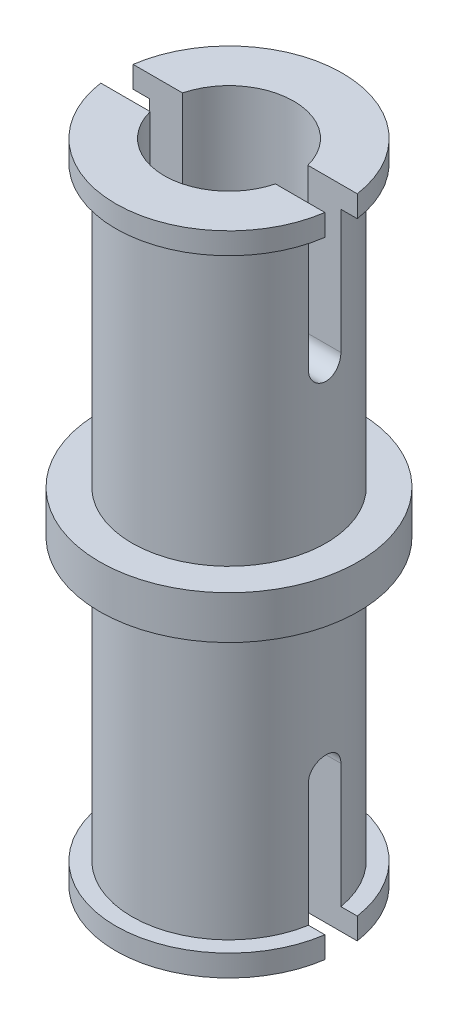
from build123d import *

# Parameters (mm, degrees)
SKETCH1_R               = 1.5
SKETCH1_R_2             = 1
BOSS_EXTRUDE1_DEPTH     = 5
SKETCH2_R               = 2
SKETCH2_R_2             = 1
BOSS_EXTRUDE2_DEPTH     = 0.333333333
SKETCH3_R               = 1.75
SKETCH3_R_2             = 1
BOSS_EXTRUDE4_DEPTH     = 0.333333333
SKETCH4_R               = 0.25
SKETCH4_W               = 0.5
SKETCH4_H               = 2.25
CUT_EXTRUDE1_DEPTH      = 3
CUT_EXTRUDE1_DEPTH_BACK = 3


with BuildPart() as part:
    # Sketch1 → Boss-Extrude1 (new body)
    with BuildSketch(Plane(origin=(0, 0, 0), x_dir=(1, 0, 0), z_dir=(0, 1, 0))):
        Circle(SKETCH1_R)
        Circle(SKETCH1_R_2, mode=Mode.SUBTRACT)
    extrude(amount=BOSS_EXTRUDE1_DEPTH)

    # Sketch2 → Boss-Extrude2 (add)
    with BuildSketch(Plane(origin=(0, 5, 0), x_dir=(1, 0, 0), z_dir=(0, 1, 0))):
        Circle(SKETCH2_R)
        Circle(SKETCH2_R_2, mode=Mode.SUBTRACT)
    extrude(amount=-BOSS_EXTRUDE2_DEPTH)

    # Sketch3 → Boss-Extrude4 (add)
    with BuildSketch(Plane(origin=(0, 0, 0), x_dir=(-1, 0, 0), z_dir=(0, -1, 0))):
        Circle(SKETCH3_R)
        Circle(SKETCH3_R_2, mode=Mode.SUBTRACT)
    extrude(amount=-BOSS_EXTRUDE4_DEPTH)

    # Sketch4 → Cut-Extrude1 (cut, two sides)
    with BuildSketch(Plane(origin=(0, 0, 0), x_dir=(0, 0, -1), z_dir=(1, 0, 0))) as cut_extrude1_sk:
        with Locations((0, 2.25)):
            Circle(SKETCH4_R)
        with Locations((0, 1.125)):
            Rectangle(SKETCH4_W, SKETCH4_H)
    extrude(amount=CUT_EXTRUDE1_DEPTH, mode=Mode.SUBTRACT)
    extrude(cut_extrude1_sk.sketch, amount=-CUT_EXTRUDE1_DEPTH_BACK, mode=Mode.SUBTRACT)

    # Mirror1: part across plane


with BuildPart() as part_1:
    add(part.part)
    add(part.part.mirror(Plane.ZX.offset(5)))


solid = part_1.part
